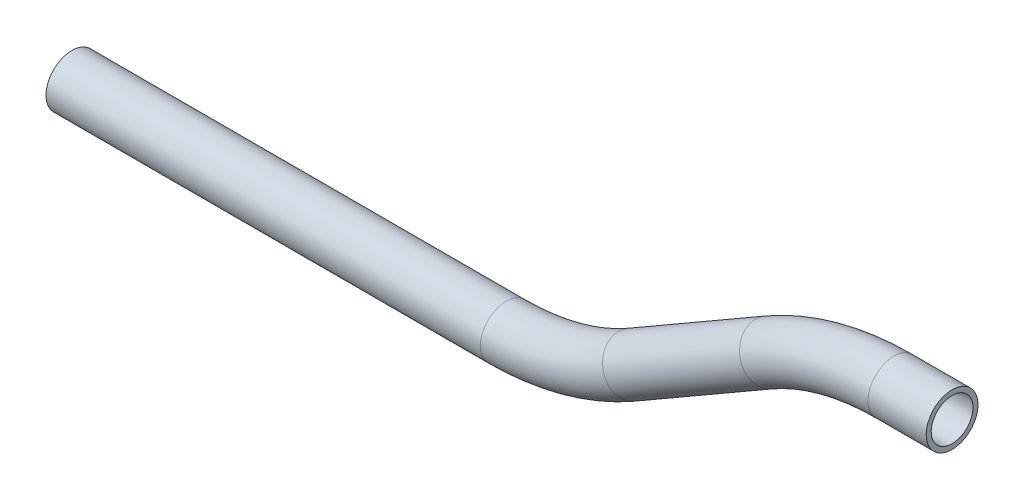
from build123d import *

# Parameters (mm, degrees)
SKETCH5_R   = 7.874
SKETCH5_R_2 = 6.35


with BuildPart() as part:
    # Sweep1: sweep along a path in Sketch4
    with BuildLine(Plane.XY) as sweep1_path:
        Line((45.216188471, 15.150806357), (27.533916935, 15.150806357))
        ThreePointArc((27.533916935, 15.150806357), (7.811905698, 12.55435432), (-10.566083065, 4.941942125))
        Line((-10.566083065, 4.941942125), (-52.191198388, -19.090329412))
        ThreePointArc((-52.191198388, -19.090329412), (-70.569187152, -26.702741607), (-90.291198388, -29.299193643))
        Line((-90.291198388, -29.299193643), (-222.273469925, -29.299193643))
    # Sketch5 → Sweep1 (sweep)
    with BuildSketch(Plane(origin=(45.216188471, 15.150806357, 0), x_dir=(0, 0, 1), z_dir=(-1, 0, 0))):
        Circle(SKETCH5_R)
        Circle(SKETCH5_R_2, mode=Mode.SUBTRACT)
    sweep(path=sweep1_path.line)


solid = part.part
